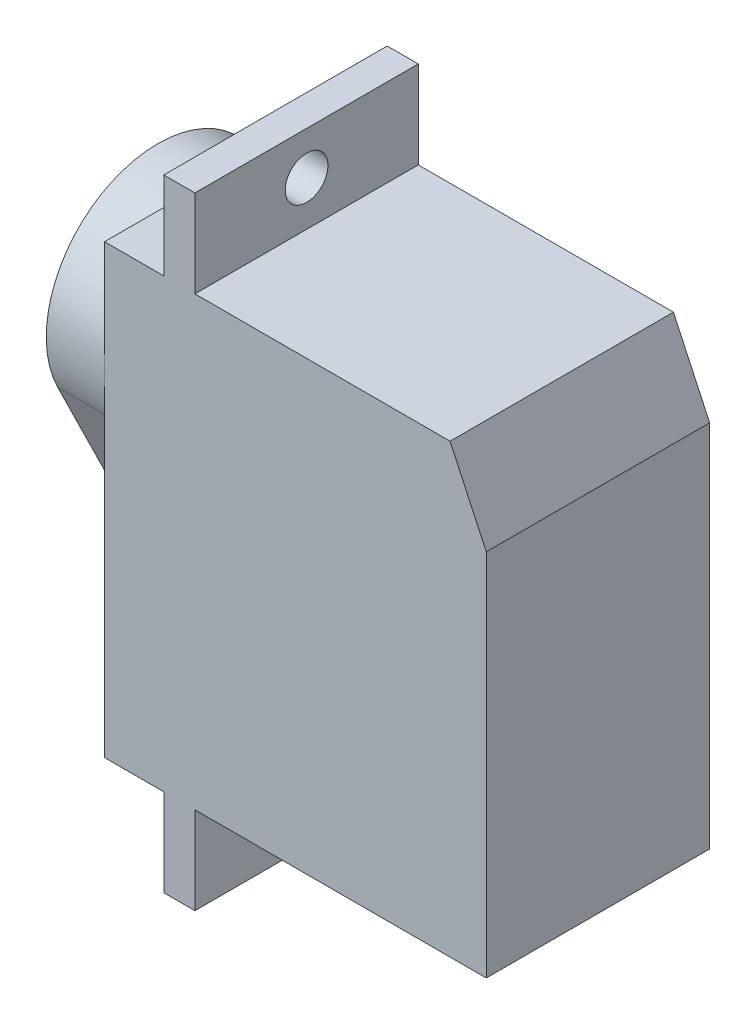
from build123d import *

# Parameters (mm, degrees)
EXTRUDE_1_DEPTH     = 11.5
SKETCH_3_R          = 1.1
CUT_EXTRUDE_1_DEPTH = 17.6
SKETCH_6_R          = 1.1
CUT_EXTRUDE_2_DEPTH = 17.6
EXTRUDE_2_DEPTH     = 3
SKETCH_8_R          = 1.1
EXTRUDE_3_DEPTH     = 3.6
SKETCH_11_R         = 2
EXTRUDE_4_DEPTH     = 2
CHAMFER_1_SIZE      = 4
CHAMFER_1_SIZE2     = 1.865230633


with BuildPart() as part:
    # 草图1 → 凸台-拉伸1 (new body)
    with BuildSketch(Plane.XY):
        Polygon((4.65, 23), (4.65, 27.5), (3.05, 27.5), (3.05, 23), (0, 23), (0, 0), (3.05, 0), (3.05, -4.5), (4.65, -4.5), (4.65, 0), (19.65, 0), (19.65, 23), align=None)
    extrude(amount=EXTRUDE_1_DEPTH)

    # 草图3 → 切除-拉伸1 (cut, through all)
    with BuildSketch(Plane.ZY.offset(-3.05)):
        with Locations((5.75, 25.3)):
            Circle(SKETCH_3_R)
    extrude(amount=-CUT_EXTRUDE_1_DEPTH, mode=Mode.SUBTRACT)

    # 草图6 → 切除-拉伸2 (cut, through all)
    with BuildSketch(Plane.ZY.offset(-3.05)):
        with Locations((5.75, -2.3)):
            Circle(SKETCH_6_R)
    extrude(amount=-CUT_EXTRUDE_2_DEPTH, mode=Mode.SUBTRACT)

    # 草图10 → 凸台-拉伸2 (add)
    with BuildSketch(Plane.ZY):
        with BuildLine():
            Line((0.589316609, 14.714285714), (3.775477659, 8.229813665))
            ThreePointArc((3.775477659, 8.229813665), (5.75, 7), (7.724522341, 8.229813665))
            Line((7.724522341, 8.229813665), (10.910683391, 14.714285714))
            ThreePointArc((10.910683391, 14.714285714), (5.75, 23), (0.589316609, 14.714285714))
        make_face()
    extrude(amount=EXTRUDE_2_DEPTH)

    # 草图8 → 凸台-拉伸3 (add)
    with BuildSketch(Plane.ZY):
        with Locations((5.75, 9.2)):
            Circle(SKETCH_8_R)
    extrude(amount=EXTRUDE_3_DEPTH)

    # 草图11 → 凸台-拉伸4 (add)
    with BuildSketch(Plane.ZY.offset(3)):
        with Locations((5.75, 17.25)):
            Circle(SKETCH_11_R)
    extrude(amount=EXTRUDE_4_DEPTH)

    # 倒角1
    chamfer_1_edges = [part.edges().sort_by_distance(p)[0] for p in [
        (19.65, 23, 5.75),
    ]]
    chamfer_1_side = [part.faces().sort_by_distance(p)[0] for p in [
        (19.65, 11.5, 5.75),
    ]]
    chamfer(chamfer_1_edges, length=CHAMFER_1_SIZE, length2=CHAMFER_1_SIZE2, reference=chamfer_1_side[0])


solid = part.part
